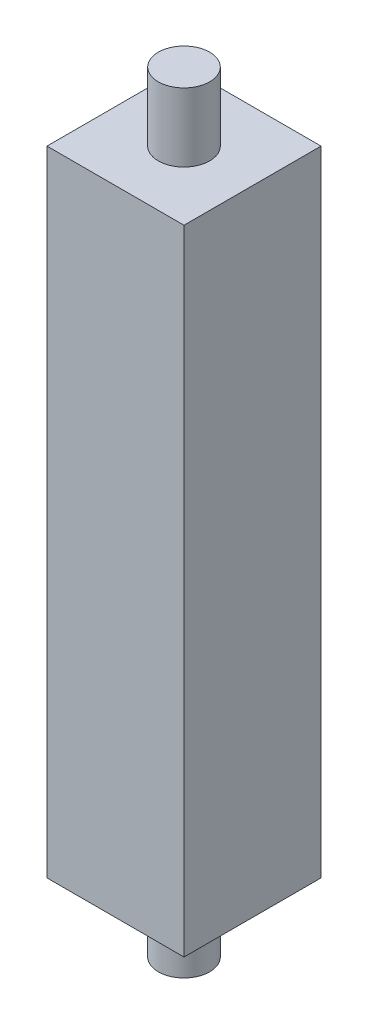
from build123d import *

# Parameters (mm, degrees)
SKETCH1_W                = 40
SKETCH1_H                = 40
BOSS_EXTRUDE1_DEPTH      = 185
SKETCH2_R                = 7.5
BOSS_EXTRUDE2_DEPTH      = 20
BOSS_EXTRUDE2_DEPTH_BACK = 205


with BuildPart() as part:
    # Sketch1 → Boss-Extrude1 (new body)
    with BuildSketch(Plane(origin=(0, 0, 0), x_dir=(1, 0, 0), z_dir=(0, 1, 0))):
        Rectangle(SKETCH1_W, SKETCH1_H)
    extrude(amount=BOSS_EXTRUDE1_DEPTH)

    # Sketch2 → Boss-Extrude2 (add, two sides)
    with BuildSketch(Plane(origin=(0, 185, 0), x_dir=(1, 0, 0), z_dir=(0, 1, 0))) as boss_extrude2_sk:
        Circle(SKETCH2_R)
    extrude(amount=BOSS_EXTRUDE2_DEPTH)
    extrude(boss_extrude2_sk.sketch, amount=-BOSS_EXTRUDE2_DEPTH_BACK)


solid = part.part
